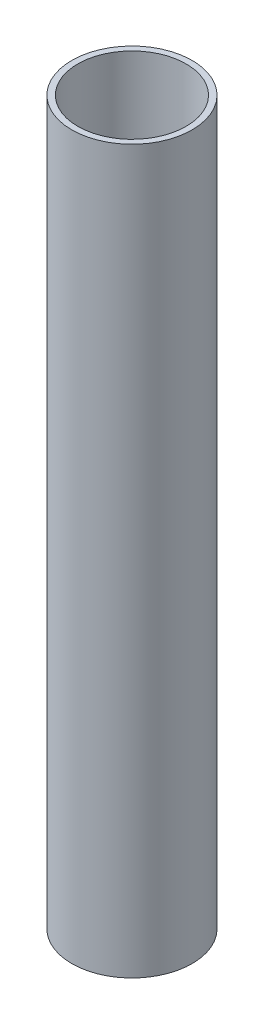
from build123d import *

# Parameters (mm, degrees)
SKETCH1_R           = 25
SKETCH1_R_2         = 22.5
BOSS_EXTRUDE1_DEPTH = 300


with BuildPart() as part:
    # Sketch1 → Boss-Extrude1 (new body)
    with BuildSketch(Plane(origin=(0, 0, 0), x_dir=(1, 0, 0), z_dir=(0, 1, 0))):
        Circle(SKETCH1_R)
        Circle(SKETCH1_R_2, mode=Mode.SUBTRACT)
    extrude(amount=BOSS_EXTRUDE1_DEPTH)


solid = part.part
